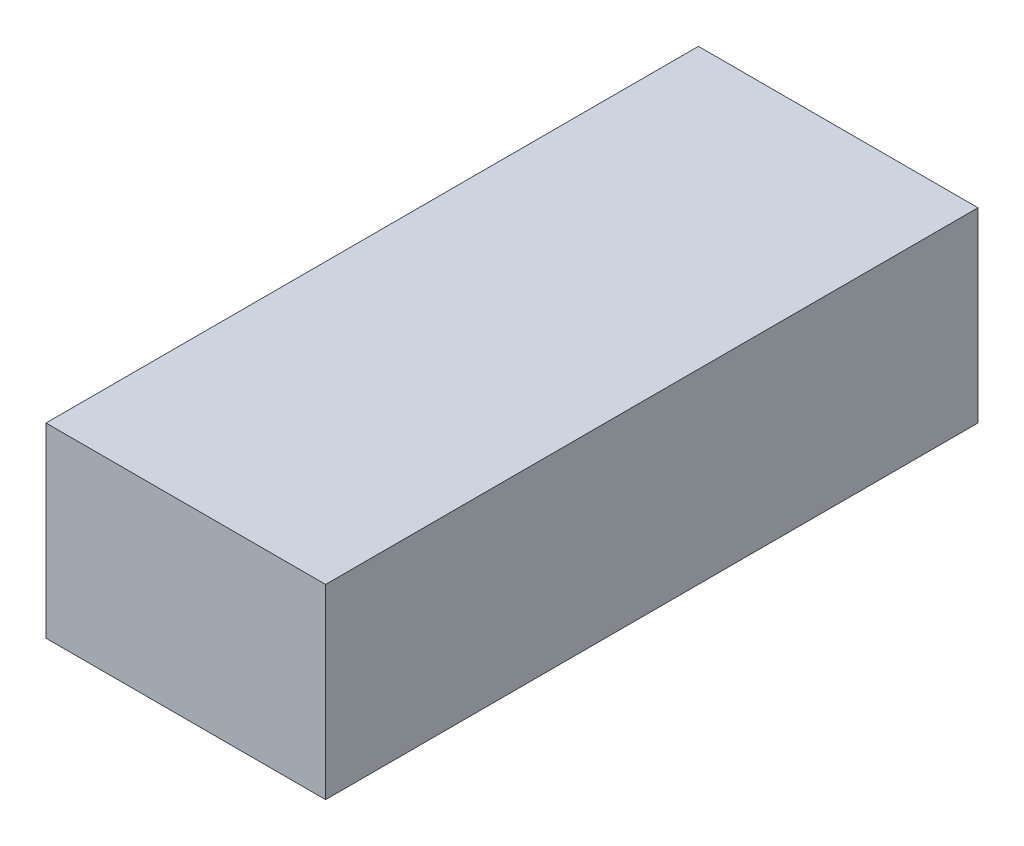
from build123d import *

# Parameters (mm, degrees)
SKETCH1_W           = 30.48
SKETCH1_H           = 71.12
BOSS_EXTRUDE1_DEPTH = 20.32


with BuildPart() as part:
    # Sketch1 → Boss-Extrude1 (new body)
    with BuildSketch(Plane(origin=(0, 0, 0), x_dir=(1, 0, 0), z_dir=(0, 1, 0))):
        with Locations((15.24, 35.56)):
            Rectangle(SKETCH1_W, SKETCH1_H)
    extrude(amount=BOSS_EXTRUDE1_DEPTH)


solid = part.part
